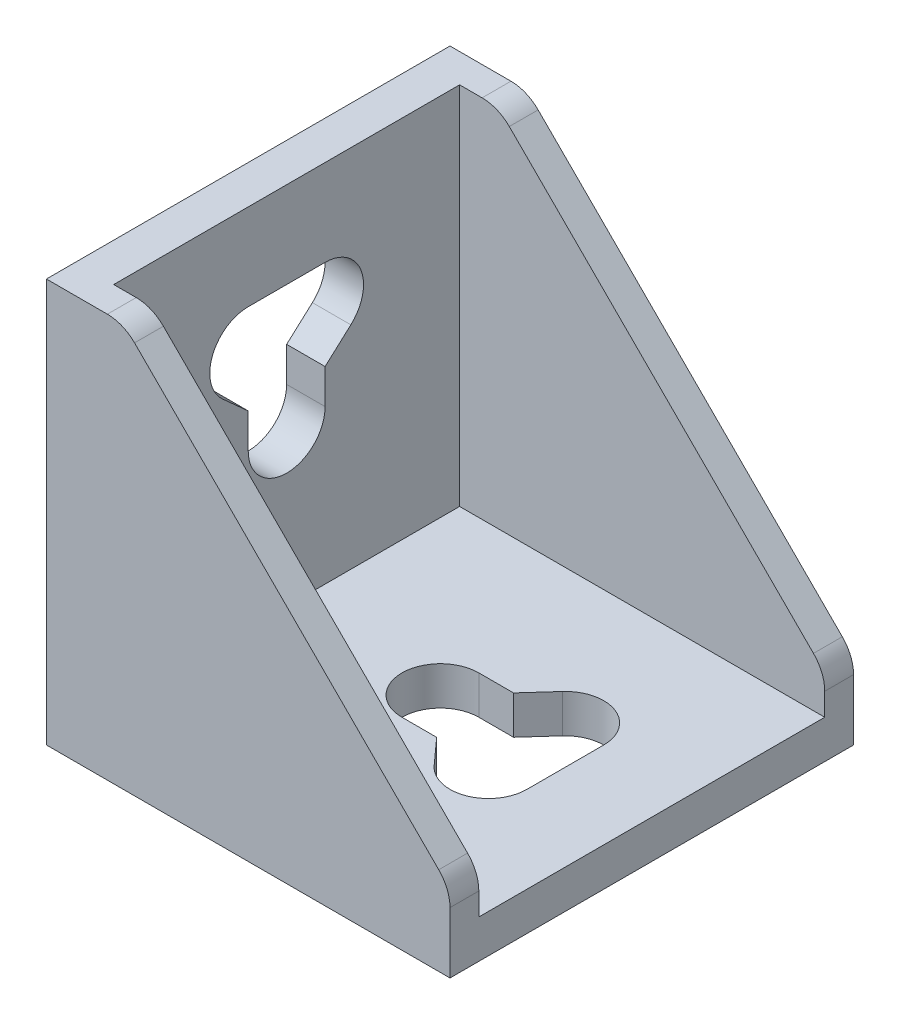
from build123d import *

# Parameters (mm, degrees)
EXTRUDE_1_DEPTH        = 21
EXTRUDE_2_DEPTH        = 3
FILLET_1_R             = 4
FILLET_1_OF_MIRROR_2_R = 4
CUT_EXTRUDE_1_DEPTH    = 5
EXTRUDE_3_DEPTH        = 4.75


with BuildPart() as part:
    # Эскиз1 → Бобышка-Вытянуть1 (new body, symmetric)
    with BuildSketch(Plane.XY):
        Polygon((0, 42), (0, 0), (42, 0), (42, 4), (4, 4), (4, 42), align=None)
    extrude(amount=EXTRUDE_1_DEPTH, both=True)

    # Эскиз2 → Бобышка-Вытянуть2 (add)
    with BuildSketch(Plane.XY.offset(21)):
        Polygon((42, 4), (4, 4), (4, 42), (8, 42), (42, 8), align=None)
    extrude_2 = extrude(amount=-EXTRUDE_2_DEPTH)

    # Скругление1
    fillet_1_edges = [part.edges().sort_by_distance(p)[0] for p in [
        (8, 42, 19.5),
        (42, 8, 19.5),
    ]]
    fillet(fillet_1_edges, radius=FILLET_1_R)

    # Зеркальное отражение2: Бобышка-Вытянуть2 across plane
    add(extrude_2.mirror(Plane.XY))

    # Скругление1 of Зеркальное отражение2
    fillet_1_of_mirror_2_edges = [part.edges().sort_by_distance(p)[0] for p in [
        (8, 42, -19.5),
        (42, 8, -19.5),
    ]]
    fillet(fillet_1_of_mirror_2_edges, radius=FILLET_1_OF_MIRROR_2_R)

    # Эскиз3 → Вырез-Вытянуть1 (cut, through all)
    with BuildSketch(Plane(origin=(0, 4, 0), x_dir=(1, 0, 0), z_dir=(0, 1, 0))):
        with BuildLine():
            Line((20, 4), (23.611111111, 4))
            Line((23.611111111, 4), (26.030927835, 6.680412371))
            ThreePointArc((26.030927835, 6.680412371), (30.435916317, 7.733382425), (33, 4))
            Line((33, 4), (33, -4))
            ThreePointArc((33, -4), (30.435916317, -7.733382425), (26.030927835, -6.680412371))
            Line((26.030927835, -6.680412371), (23.611111111, -4))
            Line((23.611111111, -4), (20, -4))
            ThreePointArc((20, -4), (16, 0), (20, 4))
        make_face()
    cut_extrude_1 = extrude(amount=-CUT_EXTRUDE_1_DEPTH, mode=Mode.SUBTRACT)

    # Эскиз4 → Бобышка-Вытянуть3 (add, symmetric)
    with BuildSketch(Plane.XY):
        Polygon((1.232233047, 0), (0, -1.232233047), (1.767766953, -3), (4.767766953, 0), align=None)
        Polygon((42, 0), (39, -3), (37.232233047, -1.232233047), (38.464466094, 0), align=None)
    extrude_3 = extrude(amount=EXTRUDE_3_DEPTH, both=True)

    # Зеркальное отражение3: Вырез-Вытянуть1, Бобышка-Вытянуть3 across plane
    add(cut_extrude_1.mirror(Plane(origin=(0, 0, 0), x_dir=(0, 0, 1), z_dir=(-0.707106781, 0.707106781, 0))), mode=Mode.SUBTRACT)
    add(extrude_3.mirror(Plane(origin=(0, 0, 0), x_dir=(0, 0, 1), z_dir=(-0.707106781, 0.707106781, 0))))


solid = part.part
